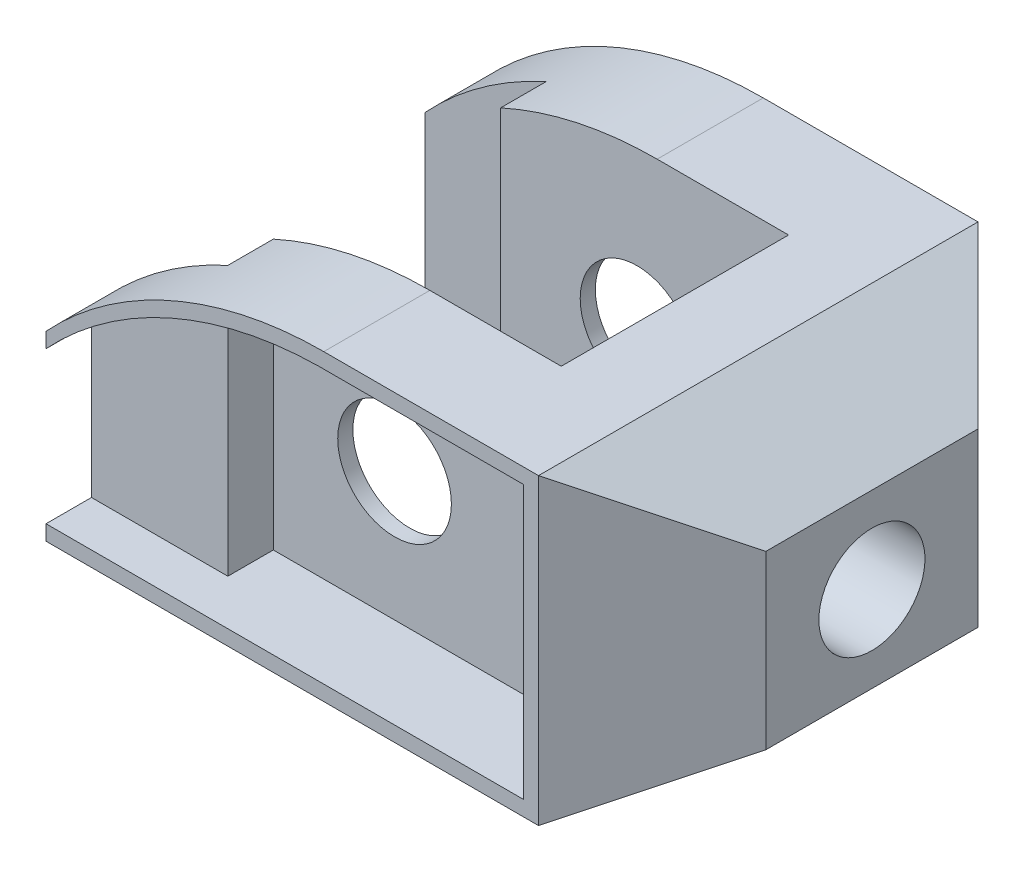
from build123d import *

# Parameters (mm, degrees)
SKETCH2_W                = 80
SKETCH2_H                = 58
BOSS_EXTRUDE1_DEPTH      = 40
CUT_EXTRUDE7_DEPTH       = 58
CUT_EXTRUDE7_DEPTH_BACK  = 58
SKETCH4_R                = 7.5
SKETCH12_W               = 54
SKETCH12_H               = 30
CUT_EXTRUDE10_DEPTH      = 58
CUT_EXTRUDE11_DEPTH      = 58
CUT_EXTRUDE11_DEPTH_BACK = 58
SKETCH14_W               = 16
SKETCH14_H               = 6
CUT_EXTRUDE12_DEPTH      = 58
CUT_EXTRUDE12_DEPTH_BACK = 58
SKETCH17_R               = 7
CUT_EXTRUDE14_DEPTH      = 58
CUT_EXTRUDE14_DEPTH_BACK = 58
SKETCH20_R               = 7.5
CUT_EXTRUDE15_DEPTH      = 12
CUT_EXTRUDE16_DEPTH      = 6
CUT_EXTRUDE17_START      = -12
SKETCH23_R               = 7.5
CUT_EXTRUDE17_DEPTH      = 12
CUT_EXTRUDE18_START      = -6
CUT_EXTRUDE18_DEPTH      = 6


with BuildPart() as part:
    # Sketch2 → Boss-Extrude1 (new body)
    with BuildSketch(Plane(origin=(0, 0, 0), x_dir=(1, 0, 0), z_dir=(0, 1, 0))):
        Rectangle(SKETCH2_W, SKETCH2_H)
    extrude(amount=BOSS_EXTRUDE1_DEPTH)

    # Sketch4 → Cut-Extrude7 (cut, two sides: drawn at the far end of the back side and taken through both)
    with BuildSketch(Plane.XY.offset(-CUT_EXTRUDE7_DEPTH_BACK)):
        Polygon((25, 0), (40, 0), (40, 8.660254038), align=None)
        Polygon((25, 40), (40, 31.339745962), (40, 40), align=None)
        with BuildLine():
            Line((-40, 40), (-40, 24))
            ThreePointArc((-40, 24), (-23.33939444, 35.82575695), (-3.33939444, 40))
            Line((-3.33939444, 40), (-40, 40))
        make_face()
        with Locations((-6, 19)):
            Circle(SKETCH4_R)
    extrude(amount=CUT_EXTRUDE7_DEPTH + CUT_EXTRUDE7_DEPTH_BACK, mode=Mode.SUBTRACT)

    # Sketch12 → Cut-Extrude10 (cut)
    with BuildSketch(Plane(origin=(0, 40, 0), x_dir=(1, 0, 0), z_dir=(0, 1, 0))):
        with Locations((-13, 0)):
            Rectangle(SKETCH12_W, SKETCH12_H)
    extrude(amount=-CUT_EXTRUDE10_DEPTH, mode=Mode.SUBTRACT)

    # Sketch14 → Cut-Extrude11 (cut, two sides: drawn at the far end of the back side and taken through both)
    with BuildSketch(Plane(origin=(0, 40, 0), x_dir=(1, 0, 0), z_dir=(0, 1, 0)).offset(-CUT_EXTRUDE11_DEPTH_BACK)):
        with Locations((-32, 18)):
            Rectangle(SKETCH14_W, SKETCH14_H)
        with Locations((-32, -18)):
            Rectangle(SKETCH14_W, SKETCH14_H)
    extrude(amount=CUT_EXTRUDE11_DEPTH + CUT_EXTRUDE11_DEPTH_BACK, mode=Mode.SUBTRACT)

    # Sketch17 → Cut-Extrude12 (cut, two sides: drawn at the far end of the back side and taken through both)
    with BuildSketch(Plane(origin=(40, 0, 0), x_dir=(0, 0, -1), z_dir=(1, 0, 0)).offset(-CUT_EXTRUDE12_DEPTH_BACK)):
        with Locations((0, 20)):
            Circle(SKETCH17_R)
    extrude(amount=CUT_EXTRUDE12_DEPTH + CUT_EXTRUDE12_DEPTH_BACK, mode=Mode.SUBTRACT)

    # Sketch19 → Cut-Extrude14 (cut, two sides: drawn at the far end of the back side and taken through both)
    with BuildSketch(Plane(origin=(0, 40, 0), x_dir=(1, 0, 0), z_dir=(0, 1, 0)).offset(-CUT_EXTRUDE14_DEPTH_BACK)):
        Polygon((25, 29), (40, 29), (40, 14), align=None)
        Polygon((25, -29), (40, -14), (40, -29), align=None)
    extrude(amount=CUT_EXTRUDE14_DEPTH + CUT_EXTRUDE14_DEPTH_BACK, mode=Mode.SUBTRACT)

    # Sketch20 → Cut-Extrude15 (cut)
    with BuildSketch(Plane.XY.offset(29)):
        with BuildLine():
            Line((23, 2), (23, 38))
            Line((23, 38), (-4, 38))
            ThreePointArc((-4, 38), (-13.167101456, 37.028245592), (-22, 34.39007216))
            Line((-22, 34.39007216), (-22, 2))
            Line((-22, 2), (23, 2))
        make_face()
        with Locations((-6, 19)):
            Circle(SKETCH20_R, mode=Mode.SUBTRACT)
    extrude(amount=-CUT_EXTRUDE15_DEPTH, mode=Mode.SUBTRACT)

    # Sketch22 → Cut-Extrude16 (cut)
    with BuildSketch(Plane.XY.offset(29)):
        with BuildLine():
            Line((-22, 2), (-40, 2))
            Line((-40, 2), (-40, 22))
            ThreePointArc((-40, 22), (-31.685151748, 29.190408126), (-22, 34.39007216))
            Line((-22, 34.39007216), (-22, 2))
        make_face()
    extrude(amount=-CUT_EXTRUDE16_DEPTH, mode=Mode.SUBTRACT)

    # Sketch23 → Cut-Extrude17 (cut)
    with BuildSketch(Plane(origin=(0, 0, -29), x_dir=(-1, 0, 0), z_dir=(0, 0, -1)).offset(CUT_EXTRUDE17_START)):
        with BuildLine():
            Line((4, 38), (-23, 38))
            Line((-23, 38), (-23, 2))
            Line((-23, 2), (22, 2))
            Line((22, 2), (22, 34.39007216))
            ThreePointArc((22, 34.39007216), (13.167101456, 37.028245592), (4, 38))
        make_face()
        with Locations((6, 19)):
            Circle(SKETCH23_R, mode=Mode.SUBTRACT)
    extrude(amount=CUT_EXTRUDE17_DEPTH, mode=Mode.SUBTRACT)

    # Sketch24 → Cut-Extrude18 (cut)
    with BuildSketch(Plane(origin=(0, 0, -29), x_dir=(-1, 0, 0), z_dir=(0, 0, -1)).offset(CUT_EXTRUDE18_START)):
        with BuildLine():
            Line((22, 2), (40, 2))
            Line((40, 2), (40, 22))
            ThreePointArc((40, 22), (31.685151748, 29.190408126), (22, 34.39007216))
            Line((22, 34.39007216), (22, 2))
        make_face()
    extrude(amount=CUT_EXTRUDE18_DEPTH, mode=Mode.SUBTRACT)


solid = part.part
